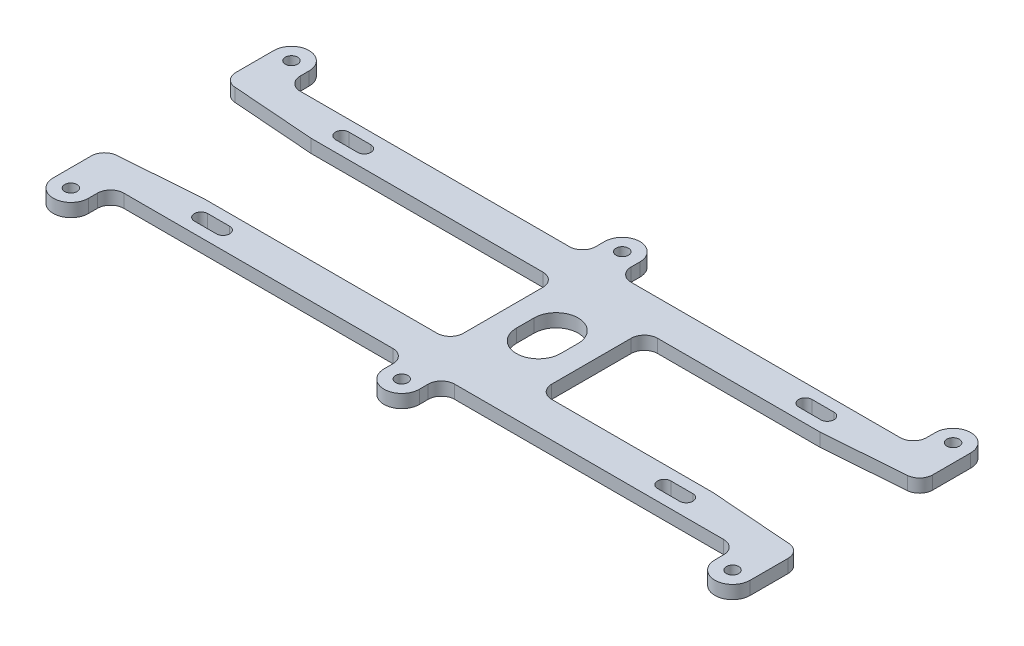
from build123d import *

# Parameters (mm, degrees)
SKETCH1_R           = 1.4
BOSS_EXTRUDE1_DEPTH = 3


with BuildPart() as part:
    # Sketch1 → Boss-Extrude1 (new body)
    with BuildSketch(Plane(origin=(0, 0, 0), x_dir=(1, 0, 0), z_dir=(0, 1, 0))):
        with BuildLine():
            Line((-76.22405565, 13.400206277), (-57.554638622, 12))
            Line((-57.554638622, 12), (-5.000314195, 12))
            ThreePointArc((-5.000314195, 12), (-2.878993852, 11.121320344), (-2.000314195, 9))
            Line((-2.000314195, 9), (-2.000314195, -9.00840207))
            ThreePointArc((-2.000314195, -9.00840207), (-2.878993852, -11.129722414), (-5.000314195, -12.00840207))
            Line((-5.000314195, -12.00840207), (-57.779008466, -12.00840207))
            Line((-57.779008466, -12.00840207), (-76.22468404, -13.391827738))
            ThreePointArc((-76.22468404, -13.391827738), (-78.199531048, -14.342973455), (-79.000314195, -16.383425668))
            Line((-79.000314195, -16.383425668), (-79.000314195, -25))
            ThreePointArc((-79.000314195, -25), (-75.000314195, -29), (-71.000314195, -25))
            Line((-71.000314195, -25), (-71.000314195, -23))
            ThreePointArc((-71.000314195, -23), (-70.121634539, -20.878679656), (-68.000314195, -20))
            Line((-68.000314195, -20), (-7.000314195, -20))
            ThreePointArc((-7.000314195, -20), (-4.878993852, -20.878679656), (-4.000314195, -23))
            Line((-4.000314195, -23), (-4.000314195, -25))
            ThreePointArc((-4.000314195, -25), (-0.000314195, -29), (3.999685805, -25))
            Line((3.999685805, -25), (3.999685805, -23))
            ThreePointArc((3.999685805, -23), (4.878365461, -20.878679656), (6.999685805, -20))
            Line((6.999685805, -20), (67.999057414, -20))
            ThreePointArc((67.999057414, -20), (70.120377758, -20.878679656), (70.999057414, -23))
            Line((70.999057414, -23), (70.999057414, -25))
            ThreePointArc((70.999057414, -25), (74.999057414, -29), (78.999057414, -25))
            Line((78.999057414, -25), (78.999057414, -16.391804207))
            ThreePointArc((78.999057414, -16.391804207), (78.198274268, -14.351351994), (76.223427259, -13.400206277))
            Line((76.223427259, -13.400206277), (57.554010231, -12))
            Line((57.554010231, -12), (20.999685805, -12))
            ThreePointArc((20.999685805, -12), (18.878365461, -11.121320344), (17.999685805, -9))
            Line((17.999685805, -9), (17.999685805, 9.00840207))
            ThreePointArc((17.999685805, 9.00840207), (18.878365461, 11.129722414), (20.999685805, 12.00840207))
            Line((20.999685805, 12.00840207), (57.778380076, 12.00840207))
            Line((57.778380076, 12.00840207), (76.22405565, 13.391827738))
            ThreePointArc((76.22405565, 13.391827738), (78.199300731, 14.342772308), (79.000314195, 16.383425668))
            Line((79.000314195, 16.383425668), (79.000314195, 25))
            ThreePointArc((79.000314195, 25), (75.000314195, 29), (71.000314195, 25))
            Line((71.000314195, 25), (71.000314195, 23))
            ThreePointArc((71.000314195, 23), (70.121634539, 20.878679656), (68.000314195, 20))
            Line((68.000314195, 20), (7.000314195, 20))
            ThreePointArc((7.000314195, 20), (4.878993852, 20.878679656), (4.000314195, 23))
            Line((4.000314195, 23), (4.000314195, 25))
            ThreePointArc((4.000314195, 25), (0.000314195, 29), (-3.999685805, 25))
            Line((-3.999685805, 25), (-3.999685805, 23))
            ThreePointArc((-3.999685805, 23), (-4.878365461, 20.878679656), (-6.999685805, 20))
            Line((-6.999685805, 20), (-67.999685805, 20))
            ThreePointArc((-67.999685805, 20), (-70.121006148, 20.878679656), (-70.999685805, 23))
            Line((-70.999685805, 23), (-70.999685805, 25))
            ThreePointArc((-70.999685805, 25), (-74.999685805, 29), (-78.999685805, 25))
            Line((-78.999685805, 25), (-78.999685805, 16.391804207))
            ThreePointArc((-78.999685805, 16.391804207), (-78.198902658, 14.351351994), (-76.22405565, 13.400206277))
        make_face()
        with Locations((74.999685805, 25)):
            Circle(SKETCH1_R, mode=Mode.SUBTRACT)
        with Locations((74.999685805, -25)):
            Circle(SKETCH1_R, mode=Mode.SUBTRACT)
        with Locations((-0.000314195, -25)):
            Circle(SKETCH1_R, mode=Mode.SUBTRACT)
        with Locations((-0.000314195, 25)):
            Circle(SKETCH1_R, mode=Mode.SUBTRACT)
        with Locations((-75.000314195, 25)):
            Circle(SKETCH1_R, mode=Mode.SUBTRACT)
        with Locations((-75.000314195, -25)):
            Circle(SKETCH1_R, mode=Mode.SUBTRACT)
        with BuildLine():
            Line((55.499685805, -17.5), (50.499685805, -17.5))
            ThreePointArc((50.499685805, -17.5), (48.999685805, -16), (50.499685805, -14.5))
            Line((50.499685805, -14.5), (55.499685805, -14.5))
            ThreePointArc((55.499685805, -14.5), (56.999685805, -16), (55.499685805, -17.5))
        make_face(mode=Mode.SUBTRACT)
        with BuildLine():
            Line((50.499685805, 17.5), (55.499685805, 17.5))
            ThreePointArc((55.499685805, 17.5), (56.999685805, 16), (55.499685805, 14.5))
            Line((55.499685805, 14.5), (50.499685805, 14.5))
            ThreePointArc((50.499685805, 14.5), (48.999685805, 16), (50.499685805, 17.5))
        make_face(mode=Mode.SUBTRACT)
        with BuildLine():
            Line((12.999685805, 2), (12.999685805, -2))
            ThreePointArc((12.999685805, -2), (7.999685805, -7), (2.999685805, -2))
            Line((2.999685805, -2), (2.999685805, 2))
            ThreePointArc((2.999685805, 2), (7.999685805, 7), (12.999685805, 2))
        make_face(mode=Mode.SUBTRACT)
        with BuildLine():
            Line((-49.500314195, -17.5), (-54.500314195, -17.5))
            ThreePointArc((-54.500314195, -17.5), (-56.000314195, -16), (-54.500314195, -14.5))
            Line((-54.500314195, -14.5), (-49.500314195, -14.5))
            ThreePointArc((-49.500314195, -14.5), (-48.000314195, -16), (-49.500314195, -17.5))
        make_face(mode=Mode.SUBTRACT)
        with BuildLine():
            Line((-54.500314195, 17.5), (-49.500314195, 17.5))
            ThreePointArc((-49.500314195, 17.5), (-48.000314195, 16), (-49.500314195, 14.5))
            Line((-49.500314195, 14.5), (-54.500314195, 14.5))
            ThreePointArc((-54.500314195, 14.5), (-56.000314195, 16), (-54.500314195, 17.5))
        make_face(mode=Mode.SUBTRACT)
    extrude(amount=BOSS_EXTRUDE1_DEPTH)


solid = part.part
